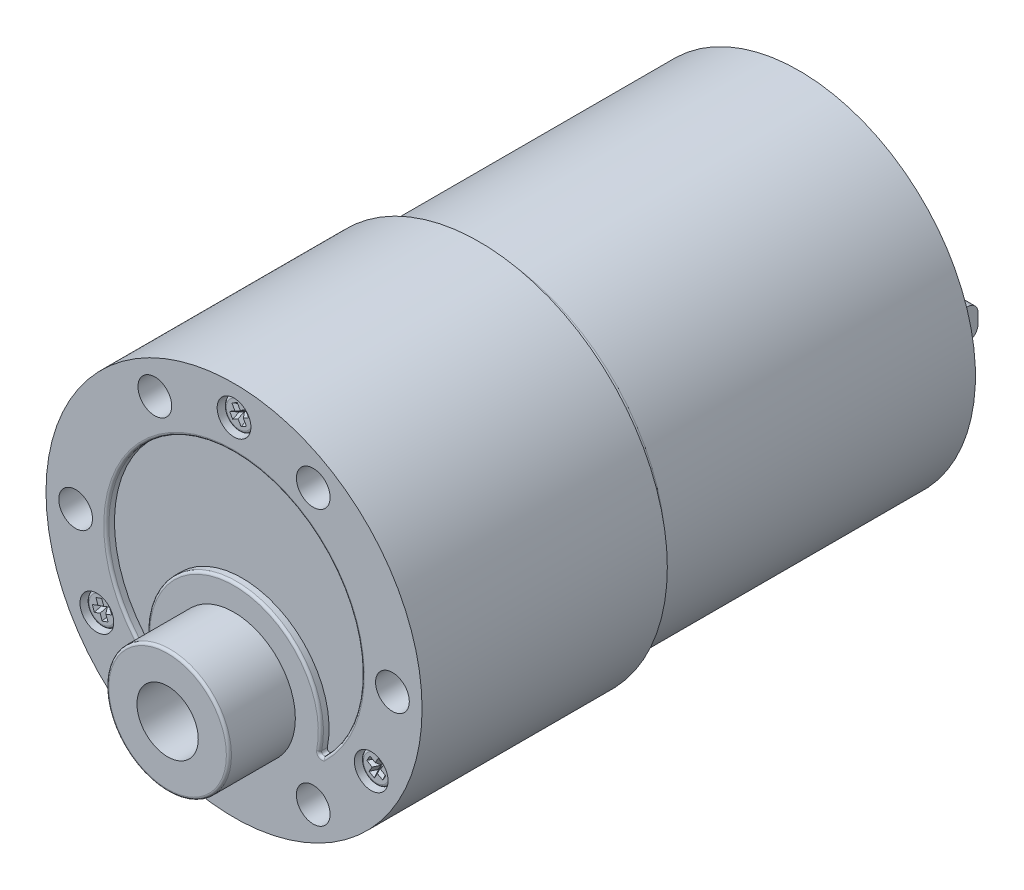
from build123d import *

# Parameters (mm, degrees)
SKETCH1_R           = 18.4
BOSS_EXTRUDE1_DEPTH = 24
SKETCH2_R           = 17.25
BOSS_EXTRUDE2_DEPTH = 31.3
FILLET1_R           = 1
SKETCH4_R           = 6
SKETCH4_R_2         = 3
BOSS_EXTRUDE4_DEPTH = 6.5
FILLET2_R           = 0.25
SKETCH5_R           = 1.65
CUT_EXTRUDE1_DEPTH  = 5
SKETCH5_3_R         = 1.65
CUT_EXTRUDE2_DEPTH  = 1
SKETCH6_R           = 1.5
BOSS_EXTRUDE5_DEPTH = 0.5
FILLET4_R           = 0.25
CUT_EXTRUDE4_START  = 0.5
CUT_EXTRUDE4_DEPTH  = 0.5
CUT_EXTRUDE4_TAPER  = 30
CUT_EXTRUDE5_DEPTH  = 0.8
FILLET5_R           = 0.25
FILLET7_R           = 0.25
SKETCH8_R           = 4
BOSS_EXTRUDE6_DEPTH = 1.25
FILLET8_R           = 0.5
SKETCH9_W           = 1
SKETCH9_H           = 3
BOSS_EXTRUDE7_DEPTH = 5
FILLET9_R           = 1
CUT_EXTRUDE6_DEPTH  = 5
CUT_EXTRUDE7_START  = 24
CUT_EXTRUDE7_DEPTH  = 5


with BuildPart() as part:
    # Sketch1 → Boss-Extrude1 (new body)
    with BuildSketch(Plane.XY):
        Circle(SKETCH1_R)
    extrude(amount=-BOSS_EXTRUDE1_DEPTH)

    # Sketch4 → Boss-Extrude4 (add)
    with BuildSketch(Plane.XY):
        with Locations((0, -7)):
            Circle(SKETCH4_R)
        with Locations((0, -7)):
            Circle(SKETCH4_R_2, mode=Mode.SUBTRACT)
    extrude(amount=BOSS_EXTRUDE4_DEPTH)

    # Fillet2
    fillet2_edges = [part.edges().sort_by_distance(p)[0] for p in [
        (-6, -7, 6.5),
    ]]
    fillet(fillet2_edges, radius=FILLET2_R)

    # Sketch5 → Cut-Extrude1 (cut)
    with BuildSketch(Plane.XY):
        with Locations((-15.5, 0)):
            Circle(SKETCH5_R)
        with Locations((-7.75, 13.423393759)):
            Circle(SKETCH5_R)
        with Locations((7.75, 13.423393759)):
            Circle(SKETCH5_R)
        with Locations((15.5, 0)):
            Circle(SKETCH5_R)
        with Locations((7.75, -13.423393759)):
            Circle(SKETCH5_R)
        with Locations((-7.75, -13.423393759)):
            Circle(SKETCH5_R)
    extrude(amount=-CUT_EXTRUDE1_DEPTH, mode=Mode.SUBTRACT)

    # Sketch5_3 → Cut-Extrude2 (cut)
    with BuildSketch(Plane.XY):
        with Locations((0, 15.5)):
            Circle(SKETCH5_3_R)
        with Locations((13.423393759, -7.75)):
            Circle(SKETCH5_3_R)
        with Locations((-13.423393759, -7.75)):
            Circle(SKETCH5_3_R)
    extrude(amount=-CUT_EXTRUDE2_DEPTH, mode=Mode.SUBTRACT)

    # Sketch6 → Boss-Extrude5 (add)
    with BuildSketch(Plane.XY.offset(-1)):
        with Locations((-13.423393759, -7.75)):
            Circle(SKETCH6_R)
        Polygon((-13.807907588, -7.570698257), (-14.37172316, -7.775910343), (-14.166511074, -8.339725915), (-13.602695502, -8.134513829), (-13.397483416, -8.698329402), (-12.833667843, -8.493117316), (-13.038879929, -7.929301743), (-12.475064357, -7.724089657), (-12.680276443, -7.160274085), (-13.244092015, -7.365486171), (-13.449304101, -6.801670598), (-14.013119674, -7.006882684), align=None, mode=Mode.SUBTRACT)
        with Locations((0, 15.5)):
            Circle(SKETCH6_R)
        Polygon((-0.409807621, 15.609807621), (-0.929422863, 15.309807621), (-0.629422863, 14.790192379), (-0.109807621, 15.090192379), (0.190192379, 14.570577137), (0.709807621, 14.870577137), (0.409807621, 15.390192379), (0.929422863, 15.690192379), (0.629422863, 16.209807621), (0.109807621, 15.909807621), (-0.190192379, 16.429422863), (-0.709807621, 16.129422863), align=None, mode=Mode.SUBTRACT)
        with Locations((13.423393759, -7.75)):
            Circle(SKETCH6_R)
        Polygon((13.013586138, -7.859807621), (12.713586138, -8.379422863), (13.23320138, -8.679422863), (13.53320138, -8.159807621), (14.052816622, -8.459807621), (14.352816622, -7.940192379), (13.83320138, -7.640192379), (14.13320138, -7.120577137), (13.613586138, -6.820577137), (13.313586138, -7.340192379), (12.793970895, -7.040192379), (12.493970895, -7.559807621), align=None, mode=Mode.SUBTRACT)
        Polygon((-14.013119674, -7.006882684), (-13.807907588, -7.570698257), (-14.37172316, -7.775910343), (-14.166511074, -8.339725915), (-13.602695502, -8.134513829), (-13.397483416, -8.698329402), (-12.833667843, -8.493117316), (-13.038879929, -7.929301743), (-12.475064357, -7.724089657), (-12.680276443, -7.160274085), (-13.244092015, -7.365486171), (-13.449304101, -6.801670598), align=None)
        Polygon((-0.709807621, 16.129422863), (-0.409807621, 15.609807621), (-0.929422863, 15.309807621), (-0.629422863, 14.790192379), (-0.109807621, 15.090192379), (0.190192379, 14.570577137), (0.709807621, 14.870577137), (0.409807621, 15.390192379), (0.929422863, 15.690192379), (0.629422863, 16.209807621), (0.109807621, 15.909807621), (-0.190192379, 16.429422863), align=None)
        Polygon((12.493970895, -7.559807621), (13.013586138, -7.859807621), (12.713586138, -8.379422863), (13.23320138, -8.679422863), (13.53320138, -8.159807621), (14.052816622, -8.459807621), (14.352816622, -7.940192379), (13.83320138, -7.640192379), (14.13320138, -7.120577137), (13.613586138, -6.820577137), (13.313586138, -7.340192379), (12.793970895, -7.040192379), align=None)
    extrude(amount=BOSS_EXTRUDE5_DEPTH)

    # Fillet4
    fillet4_edges = [part.edges().sort_by_distance(p)[0] for p in [
        (-14.923393759, -7.75, -0.5),
        (-1.5, 15.5, -0.5),
        (11.923393759, -7.75, -0.5),
    ]]
    fillet(fillet4_edges, radius=FILLET4_R)

    # Sketch6_5 → Cut-Extrude4 (cut)
    with BuildSketch(Plane.XY.offset(-1).offset(CUT_EXTRUDE4_START)):
        Polygon((-0.929422863, 15.309807621), (-0.629422863, 14.790192379), (-0.109807621, 15.090192379), (0.190192379, 14.570577137), (0.709807621, 14.870577137), (0.409807621, 15.390192379), (0.929422863, 15.690192379), (0.629422863, 16.209807621), (0.109807621, 15.909807621), (-0.190192379, 16.429422863), (-0.709807621, 16.129422863), (-0.409807621, 15.609807621), align=None)
        Polygon((-14.37172316, -7.775910343), (-14.166511074, -8.339725915), (-13.602695502, -8.134513829), (-13.397483416, -8.698329402), (-12.833667843, -8.493117316), (-13.038879929, -7.929301743), (-12.475064357, -7.724089657), (-12.680276443, -7.160274085), (-13.244092015, -7.365486171), (-13.449304101, -6.801670598), (-14.013119674, -7.006882684), (-13.807907588, -7.570698257), align=None)
        Polygon((12.713586138, -8.379422863), (13.23320138, -8.679422863), (13.53320138, -8.159807621), (14.052816622, -8.459807621), (14.352816622, -7.940192379), (13.83320138, -7.640192379), (14.13320138, -7.120577137), (13.613586138, -6.820577137), (13.313586138, -7.340192379), (12.793970895, -7.040192379), (12.493970895, -7.559807621), (13.013586138, -7.859807621), align=None)
    extrude(amount=-CUT_EXTRUDE4_DEPTH, taper=CUT_EXTRUDE4_TAPER, mode=Mode.SUBTRACT)

    # Sketch7 → Cut-Extrude5 (cut)
    with BuildSketch(Plane.XY):
        with BuildLine():
            ThreePointArc((8.124038405, -9.5), (11.353424154, -5.229699797), (12.5, 0))
            ThreePointArc((12.5, 0), (-5.229699797, 11.353424154), (-8.124038405, -9.5))
            ThreePointArc((-8.124038405, -9.5), (-1.264055687, 1.405484116), (8.5, -7))
            ThreePointArc((8.5, -7), (8.405484116, -8.264055687), (8.124038405, -9.5))
        make_face()
    extrude(amount=-CUT_EXTRUDE5_DEPTH, mode=Mode.SUBTRACT)

    # Fillet5
    fillet5_edges = [part.edges().sort_by_distance(p)[0] for p in [
        (8.124038405, -9.5, -0.4),
        (-8.124038405, -9.5, -0.4),
    ]]
    fillet(fillet5_edges, radius=FILLET5_R)

    # Fillet7
    fillet7_edges = [part.edges().sort_by_distance(p)[0] for p in [
        (0, 12.5, 0),
        (-0.854326177, 1.456957301, 0),
        (8.453691239, -8.969577516, 0),
        (-8.453691239, -8.969577516, 0),
    ]]
    fillet(fillet7_edges, radius=FILLET7_R)


with BuildPart() as body_2:
    # Sketch2 → Boss-Extrude2 (new body)
    with BuildSketch(Plane(origin=(0, 0, -24), x_dir=(-1, 0, 0), z_dir=(0, 0, -1))):
        Circle(SKETCH2_R)
    extrude(amount=BOSS_EXTRUDE2_DEPTH)

    # Fillet1
    fillet1_edges = [body_2.edges().sort_by_distance(p)[0] for p in [
        (17.25, 0, -24),
    ]]
    fillet(fillet1_edges, radius=FILLET1_R)

    # Sketch8 → Boss-Extrude6 (add)
    with BuildSketch(Plane(origin=(0, 0, -55.3), x_dir=(-1, 0, 0), z_dir=(0, 0, -1))):
        Circle(SKETCH8_R)
    extrude(amount=BOSS_EXTRUDE6_DEPTH)

    # Fillet8
    fillet8_edges = [body_2.edges().sort_by_distance(p)[0] for p in [
        (4, 0, -56.55),
    ]]
    fillet(fillet8_edges, radius=FILLET8_R)

    # Sketch9 → Boss-Extrude7 (add)
    with BuildSketch(Plane(origin=(0, 0, -55.3), x_dir=(-1, 0, 0), z_dir=(0, 0, -1))):
        with Locations((-12, 0)):
            Rectangle(SKETCH9_W, SKETCH9_H)
        with Locations((12, 0)):
            Rectangle(SKETCH9_W, SKETCH9_H)
    extrude(amount=BOSS_EXTRUDE7_DEPTH)

    # Fillet9
    fillet9_edges = [body_2.edges().sort_by_distance(p)[0] for p in [
        (12, 1.5, -60.3),
        (12, -1.5, -60.3),
        (-12, 1.5, -60.3),
        (-12, -1.5, -60.3),
    ]]
    fillet(fillet9_edges, radius=FILLET9_R)

    # Sketch10 → Cut-Extrude6 (cut)
    with BuildSketch(Plane(origin=(-11.5, 0, 0), x_dir=(0, 0, -1), z_dir=(1, 0, 0))):
        with BuildLine():
            Line((58.569188747, -0.788023881), (56.738403492, -0.788023881))
            ThreePointArc((56.738403492, -0.788023881), (55.950379611, 0), (56.738403492, 0.788023881))
            Line((56.738403492, 0.788023881), (58.569188747, 0.788023881))
            ThreePointArc((58.569188747, 0.788023881), (59.357212627, 0), (58.569188747, -0.788023881))
        make_face()
    extrude(amount=-CUT_EXTRUDE6_DEPTH, mode=Mode.SUBTRACT)

    # Sketch10_2 → Cut-Extrude7 (cut)
    with BuildSketch(Plane(origin=(-11.5, 0, 0), x_dir=(0, 0, -1), z_dir=(1, 0, 0)).offset(CUT_EXTRUDE7_START)):
        with BuildLine():
            Line((58.569188747, -0.788023881), (56.738403492, -0.788023881))
            ThreePointArc((56.738403492, -0.788023881), (55.950379611, 0), (56.738403492, 0.788023881))
            Line((56.738403492, 0.788023881), (58.569188747, 0.788023881))
            ThreePointArc((58.569188747, 0.788023881), (59.357212627, 0), (58.569188747, -0.788023881))
        make_face()
    extrude(amount=-CUT_EXTRUDE7_DEPTH, mode=Mode.SUBTRACT)


solid = Compound([part.part, body_2.part])
